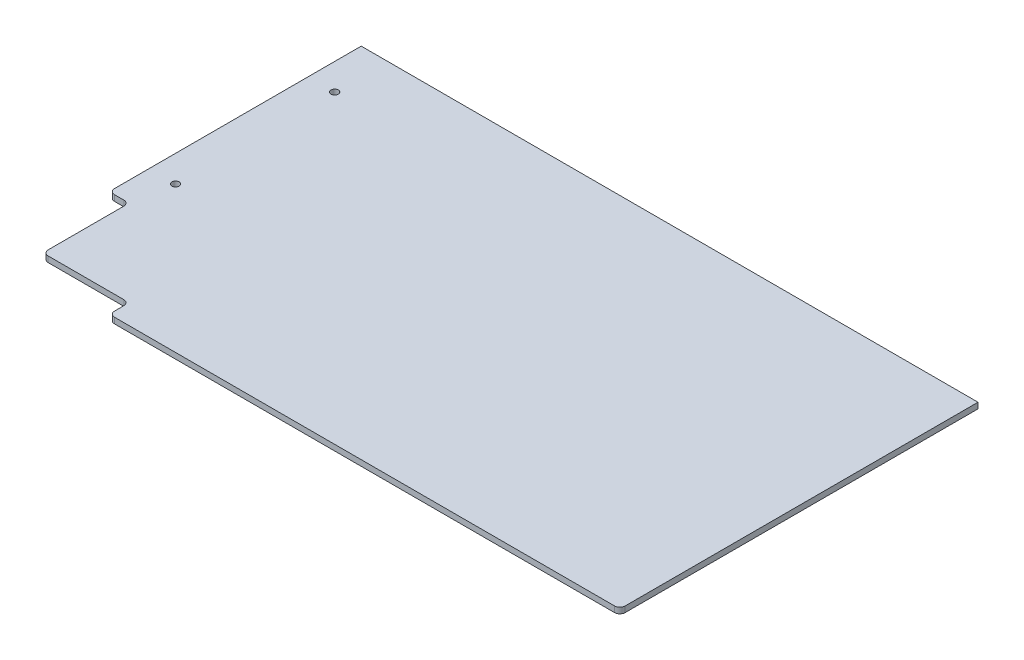
from build123d import *

# Parameters (mm, degrees)
SKETCH1_W           = 304.8
SKETCH1_H           = 190.5
BOSS_EXTRUDE1_DEPTH = 2.778125
SKETCH2_W           = 304.8
SKETCH2_H           = 19.05
CUT_EXTRUDE1_DEPTH  = 3.778125
CUT_EXTRUDE2_DEPTH  = 3.778125
SKETCH4_R           = 1.7526
CUT_EXTRUDE3_DEPTH  = 3.778125
SKETCH5_W           = 9.525
SKETCH5_H           = 171.45
CUT_EXTRUDE4_DEPTH  = 3.778125
FILLET1_R           = 2.54


with BuildPart() as part:
    # Sketch1 → Boss-Extrude1 (new body)
    with BuildSketch(Plane(origin=(0, 0, 0), x_dir=(1, 0, 0), z_dir=(0, 1, 0))):
        with Locations((152.4, 95.25)):
            Rectangle(SKETCH1_W, SKETCH1_H)
    extrude(amount=BOSS_EXTRUDE1_DEPTH)

    # Sketch2 → Cut-Extrude1 (cut, through all)
    with BuildSketch(Plane(origin=(0, 2.778125, 0), x_dir=(1, 0, 0), z_dir=(0, 1, 0))):
        with Locations((152.4, 9.525)):
            Rectangle(SKETCH2_W, SKETCH2_H)
    extrude(amount=-CUT_EXTRUDE1_DEPTH, mode=Mode.SUBTRACT)

    # Sketch3 → Cut-Extrude2 (cut, through all)
    with BuildSketch(Plane(origin=(0, 2.778125, 0), x_dir=(1, 0, 0), z_dir=(0, 1, 0))):
        Polygon((0, 19.05), (0, 69.85), (9.525, 69.85), (9.525, 28.575), (50.8, 28.575), (50.8, 19.05), align=None)
    extrude(amount=-CUT_EXTRUDE2_DEPTH, mode=Mode.SUBTRACT)

    # Sketch4 → Cut-Extrude3 (cut, through all)
    with BuildSketch(Plane(origin=(0, 2.778125, 0), x_dir=(1, 0, 0), z_dir=(0, 1, 0))):
        with Locations((12.7, 165.1)):
            Circle(SKETCH4_R)
        with Locations((12.7, 88.9)):
            Circle(SKETCH4_R)
    extrude(amount=-CUT_EXTRUDE3_DEPTH, mode=Mode.SUBTRACT)

    # Sketch5 → Cut-Extrude4 (cut, through all)
    with BuildSketch(Plane(origin=(0, 2.778125, 0), x_dir=(1, 0, 0), z_dir=(0, 1, 0))):
        with Locations((300.0375, 104.775)):
            Rectangle(SKETCH5_W, SKETCH5_H)
    extrude(amount=-CUT_EXTRUDE4_DEPTH, mode=Mode.SUBTRACT)

    # Fillet1
    fillet1_edges = [part.edges().sort_by_distance(p)[0] for p in [
        (50.8, 1.3890625, -19.05),
        (0, 1.3890625, -69.85),
        (9.525, 1.3890625, -69.85),
        (9.525, 1.3890625, -28.575),
        (50.8, 1.3890625, -28.575),
        (295.275, 1.3890625, -19.05),
    ]]
    fillet(fillet1_edges, radius=FILLET1_R)


solid = part.part
